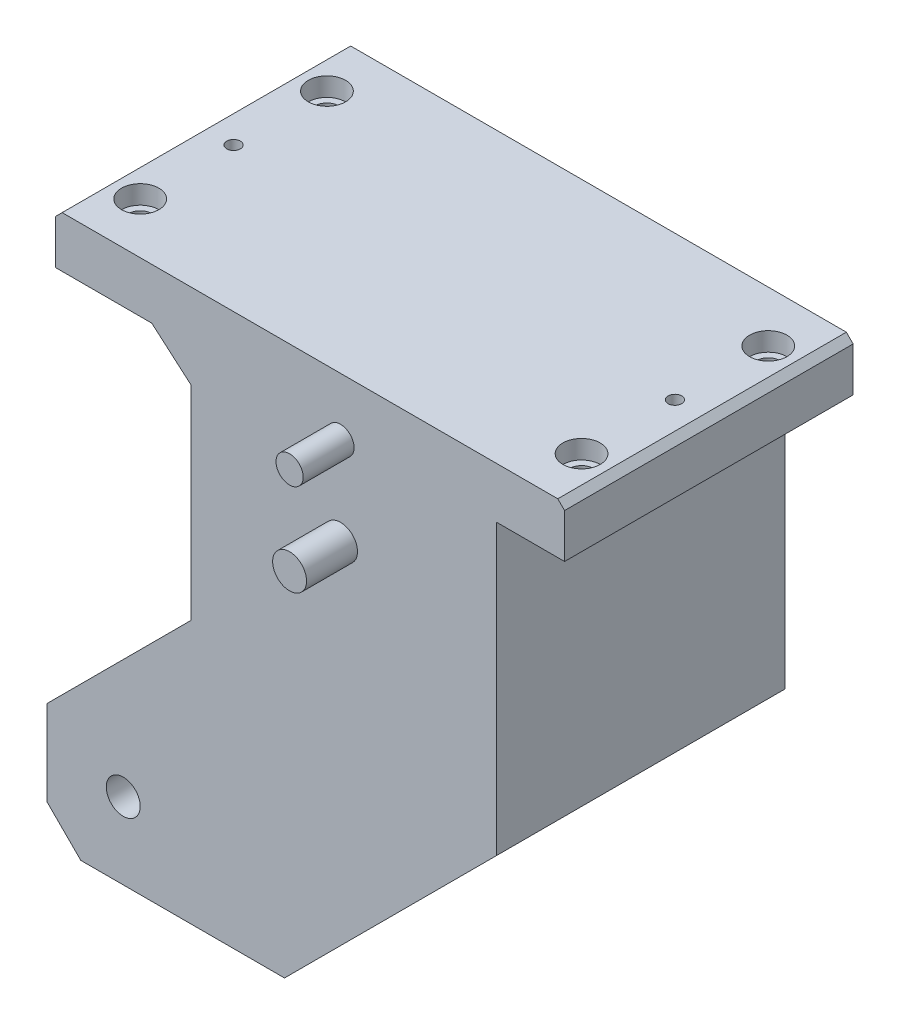
from build123d import *

# Parameters (mm, degrees)
ESQUISSE1_R             = 5
BOSS_EXTRU_1_DEPTH      = 85
ESQUISSE3_R             = 5
ESQUISSE3_R_2           = 4
BOSS_EXTRU_2_DEPTH      = 15
ESQUISSE4_R             = 3.5
ESQUISSE4_R_2           = 2
ENL_V_MAT_EXTRU_1_DEPTH = 28
ESQUISSE6_R             = 5.5
ENL_V_MAT_EXTRU_2_DEPTH = 5.5


with BuildPart() as part:
    # Esquisse1 → Boss.-Extru.1 (new body)
    with BuildSketch(Plane.XY):
        Polygon((-55.609176617, 28), (-44, 18), (-44, -42), (-86.5, -84.5), (-86.5, -109.5), (-76.5, -119.5), (-16.5, -119.5), (46, -57), (46, 28), (66, 28), (66, 41), (64, 43), (-82, 43), (-84, 41), (-84, 28), align=None)
        with Locations((-64, -97)):
            Circle(ESQUISSE1_R, mode=Mode.SUBTRACT)
    extrude(amount=-BOSS_EXTRU_1_DEPTH)

    # Esquisse3 → Boss.-Extru.2 (add)
    with BuildSketch(Plane.XY):
        Circle(ESQUISSE3_R)
        with Locations((0, 26)):
            Circle(ESQUISSE3_R_2)
    extrude(amount=BOSS_EXTRU_2_DEPTH)

    # Esquisse4 → Enlèv. mat.-Extru.1 (cut)
    with BuildSketch(Plane(origin=(0, 43, 0), x_dir=(1, 0, 0), z_dir=(0, 1, 0))):
        with Locations((-74, 70)):
            Circle(ESQUISSE4_R)
        with Locations((-74, 42.5)):
            Circle(ESQUISSE4_R_2)
        with Locations((-74, 15)):
            Circle(ESQUISSE4_R)
    enl_v_mat_extru_1 = extrude(amount=-ENL_V_MAT_EXTRU_1_DEPTH, mode=Mode.SUBTRACT)

    # Esquisse6 → Enlèv. mat.-Extru.2 (cut)
    with BuildSketch(Plane(origin=(0, 43, 0), x_dir=(1, 0, 0), z_dir=(0, 1, 0))):
        with Locations((-74, 70)):
            Circle(ESQUISSE6_R)
        with Locations((-74, 15)):
            Circle(ESQUISSE6_R)
    enl_v_mat_extru_2 = extrude(amount=-ENL_V_MAT_EXTRU_2_DEPTH, mode=Mode.SUBTRACT)

    # Symétrie1: Enlèv. mat.-Extru.1, Enlèv. mat.-Extru.2 across plane
    add(enl_v_mat_extru_1.mirror(Plane(origin=(-9, 0, 0), x_dir=(0, 0, 1), z_dir=(1, 0, 0))), mode=Mode.SUBTRACT)
    add(enl_v_mat_extru_2.mirror(Plane(origin=(-9, 0, 0), x_dir=(0, 0, 1), z_dir=(1, 0, 0))), mode=Mode.SUBTRACT)


solid = part.part
